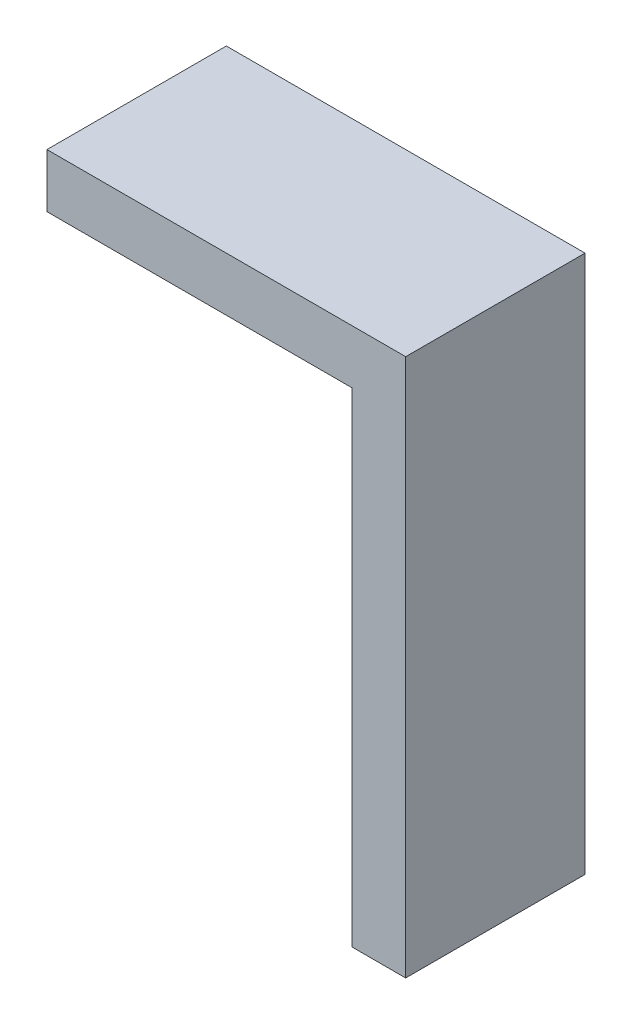
from build123d import *

# Parameters (mm, degrees)
EXTRUDE_1_DEPTH = 10


with BuildPart() as part:
    # 草图1 → 凸台-拉伸1 (new body)
    with BuildSketch(Plane.XY):
        Polygon((-47.827959467, 20.529028062), (-27.827959467, 20.529028062), (-27.827959467, -9.470971938), (-30.827959467, -9.470971938), (-30.827959467, 17.529028062), (-47.827959467, 17.529028062), align=None)
    extrude(amount=EXTRUDE_1_DEPTH)


solid = part.part
